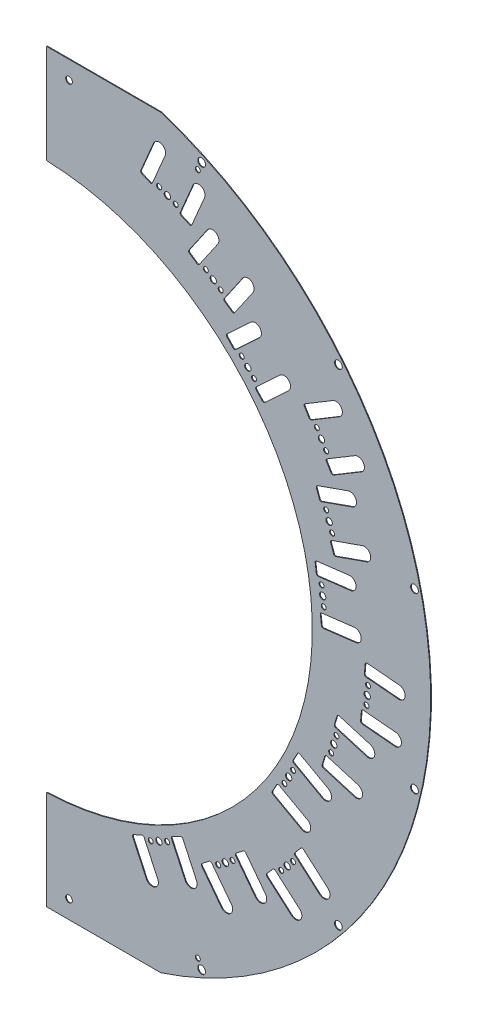
from build123d import *

# Parameters (mm, degrees)
EXTRUDE1_DEPTH                  = 0.205
EXTRUDE3_DEPTH                  = 1.41
STAVE_MOUNT_HOLE_EXTRUDE5_DEPTH = 1.41
MOUSE_HOLE_EXTRUDE7_DEPTH       = 1.205
MOUSE_HOLE_CIRPATTERN5_COUNT    = 4
MOUSE_HOLE_CIRPATTERN5_ANGLE    = 108.15757923
SKETCH14_R                      = 1.85
CUT_EXTRUDE5_DEPTH              = 1
EXTRUDE4_DEPTH                  = 0.41
SKETCH17_R                      = 2.15
SKETCH17_R_2                    = 1.375
CUT_EXTRUDE6_DEPTH              = 1.41
SKETCH18_R                      = 1.375
SKETCH18_R_2                    = 1.75
CUT_EXTRUDE7_DEPTH              = 1.41
CIRPATTERN3_COUNT               = 4
CIRPATTERN3_ANGLE               = 108.15757923


with BuildPart() as part:
    # Sketch1 → Extrude1 (new body, symmetric)
    with BuildSketch(Plane.XY):
        with BuildLine():
            Line((4.5, 217.548779521), (4.5, 151.827758069))
            ThreePointArc((4.5, 151.827758069), (22.508034536, 150.217530607), (40.197176015, 146.479026351))
            ThreePointArc((40.197176015, 146.479026351), (151.89443084, 0), (40.197176015, -146.479026351))
            ThreePointArc((40.197176015, -146.479026351), (22.508034536, -150.217530607), (4.5, -151.827758069))
            Line((4.5, -151.827758069), (4.5, -217.548779521))
            ThreePointArc((4.5, -217.548779521), (217.59531583, 0), (4.5, 217.548779521))
        make_face()
    extrude(amount=EXTRUDE1_DEPTH, both=True)

    # Sketch3 → Extrude3 (cut, through all)
    with BuildSketch(Plane.XY.offset(0.205)):
        with BuildLine():
            Line((4.5, 217.548779521), (4.5, 206.75))
            Line((4.5, 206.75), (67.839214111, 206.75))
            ThreePointArc((67.839214111, 206.75), (36.570396283, 214.500180855), (4.5, 217.548779521))
        make_face()
        with BuildLine():
            Line((67.839214111, -206.75), (4.5, -206.75))
            Line((4.5, -206.75), (4.5, -217.548779521))
            ThreePointArc((4.5, -217.548779521), (36.570396283, -214.500180855), (67.839214111, -206.75))
        make_face()
    extrude(amount=-EXTRUDE3_DEPTH, mode=Mode.SUBTRACT)

    # Sketch12 → Stave Mount Hole Extrude5 (cut, through all)
    with BuildSketch(Plane.XY.offset(0.205)):
        with BuildLine():
            Line((78.554005798, 168.04877199), (66.124274411, 173.316767591))
            ThreePointArc((66.124274411, 173.316767591), (65.741603761, 173.319895419), (65.468803041, 173.051518117))
            Line((65.468803041, 173.051518117), (64.070247765, 169.751654614))
            ThreePointArc((64.070247765, 169.751654614), (64.067119936, 169.368983964), (64.335497238, 169.096183244))
            Line((64.335497238, 169.096183244), (76.765228625, 163.828187644))
            ThreePointArc((76.765228625, 163.828187644), (77.147899275, 163.825059815), (77.420699995, 164.093437117))
            Line((77.420699995, 164.093437117), (78.819255272, 167.393300621))
            ThreePointArc((78.819255272, 167.393300621), (78.8223831, 167.77597127), (78.554005798, 168.04877199))
        make_face()
        with BuildLine():
            Line((103.782710447, 138.874719717), (92.662330225, 146.52894363))
            ThreePointArc((92.662330225, 146.52894363), (92.288064798, 146.608768433), (91.966974516, 146.400567471))
            Line((91.966974516, 146.400567471), (89.934919812, 143.448312455))
            ThreePointArc((89.934919812, 143.448312455), (89.855095009, 143.074047027), (90.063295972, 142.752956746))
            Line((90.063295972, 142.752956746), (101.183676194, 135.098732832))
            ThreePointArc((101.183676194, 135.098732832), (101.557941621, 135.018908029), (101.879031902, 135.227108992))
            Line((101.879031902, 135.227108992), (103.911086607, 138.179364008))
            ThreePointArc((103.911086607, 138.179364008), (103.990911409, 138.553629435), (103.782710447, 138.874719717))
        make_face()
        with BuildLine():
            Line((122.392786555, 104.971179279), (113.182782772, 114.841631666))
            ThreePointArc((113.182782772, 114.841631666), (112.834507043, 115.000221154), (112.47609921, 114.866092726))
            Line((112.47609921, 114.866092726), (109.855676888, 112.421007277))
            ThreePointArc((109.855676888, 112.421007277), (109.6970874, 112.072731548), (109.831215828, 111.714323715))
            Line((109.831215828, 111.714323715), (119.041219611, 101.843871328))
            ThreePointArc((119.041219611, 101.843871328), (119.38949534, 101.685281841), (119.747903172, 101.819410269))
            Line((119.747903172, 101.819410269), (122.368325495, 104.264495717))
            ThreePointArc((122.368325495, 104.264495717), (122.526914983, 104.612771447), (122.392786555, 104.971179279))
        make_face()
    extrude(amount=-STAVE_MOUNT_HOLE_EXTRUDE5_DEPTH, mode=Mode.SUBTRACT)

    # Sketch15 → Mouse Hole Extrude7 (cut, symmetric)
    with BuildSketch(Plane.XY):
        with BuildLine():
            Line((63.756596481, 189.833087254), (56.732602347, 173.260112071))
            ThreePointArc((56.732602347, 173.260112071), (56.72634669, 172.494770772), (57.263101294, 171.949169331))
            Line((57.263101294, 171.949169331), (61.866705512, 169.99805985))
            ThreePointArc((61.866705512, 169.99805985), (62.632046811, 169.991804192), (63.177648252, 170.528558797))
            Line((63.177648252, 170.528558797), (70.201642385, 187.10153398))
            ThreePointArc((70.201642385, 187.10153398), (68.34489607, 191.689833569), (63.756596481, 189.833087254))
        make_face()
        with BuildLine():
            Line((93.655811762, 163.184504516), (83.450179877, 148.357330887))
            ThreePointArc((83.450179877, 148.357330887), (83.290530271, 147.608800032), (83.706932196, 146.96661947))
            Line((83.706932196, 146.96661947), (87.825591537, 144.131721724))
            ThreePointArc((87.825591537, 144.131721724), (88.574122393, 143.972072118), (89.216302955, 144.388474043))
            Line((89.216302955, 144.388474043), (99.42193484, 159.215647672))
            ThreePointArc((99.42193484, 159.215647672), (98.523301723, 164.083137633), (93.655811762, 163.184504516))
        make_face()
        with BuildLine():
            Line((117.741552315, 130.891938027), (104.580949132, 118.611932984))
            ThreePointArc((104.580949132, 118.611932984), (104.263770157, 117.915381524), (104.532027013, 117.19856586))
            Line((104.532027013, 117.19856586), (107.943139525, 113.542842754))
            ThreePointArc((107.943139525, 113.542842754), (108.639690984, 113.225663778), (109.356506648, 113.493920635))
            Line((109.356506648, 113.493920635), (122.517109831, 125.773925678))
            ThreePointArc((122.517109831, 125.773925678), (122.688337248, 130.720710611), (117.741552315, 130.891938027))
        make_face()
        with BuildLine():
            Line((120.783733564, 101.247248228), (133.944336747, 113.527253271))
            ThreePointArc((133.944336747, 113.527253271), (138.89112168, 113.356025855), (138.719894263, 108.409240923))
            Line((138.719894263, 108.409240923), (125.55929108, 96.129235879))
            ThreePointArc((125.55929108, 96.129235879), (124.842475416, 95.860979023), (124.145923957, 96.178157998))
            Line((124.145923957, 96.178157998), (120.734811445, 99.833881105))
            ThreePointArc((120.734811445, 99.833881105), (120.466554589, 100.550696769), (120.783733564, 101.247248228))
        make_face()
        with BuildLine():
            Line((107.389223409, 130.665957432), (103.270564068, 133.500855177))
            ThreePointArc((103.270564068, 133.500855177), (102.854162143, 134.14303574), (103.013811749, 134.891566595))
            Line((103.013811749, 134.891566595), (113.219443634, 149.718740224))
            ThreePointArc((113.219443634, 149.718740224), (118.086933595, 150.617373341), (118.985566712, 145.74988338))
            Line((118.985566712, 145.74988338), (108.779934827, 130.922709751))
            ThreePointArc((108.779934827, 130.922709751), (108.137754265, 130.506307826), (107.389223409, 130.665957432))
        make_face()
        with BuildLine():
            Line((83.733825545, 160.730289812), (79.130221327, 162.681399294))
            ThreePointArc((79.130221327, 162.681399294), (78.593466723, 163.227000734), (78.59972238, 163.992342034))
            Line((78.59972238, 163.992342034), (85.623716514, 180.565317217))
            ThreePointArc((85.623716514, 180.565317217), (90.212016103, 182.422063532), (92.068762418, 177.833763942))
            Line((92.068762418, 177.833763942), (85.044768285, 161.26078876))
            ThreePointArc((85.044768285, 161.26078876), (84.499166844, 160.724034155), (83.733825545, 160.730289812))
        make_face()
    mouse_hole_extrude7 = extrude(amount=MOUSE_HOLE_EXTRUDE7_DEPTH, both=True, mode=Mode.SUBTRACT)

    # Mouse Hole CirPattern5: Mouse Hole Extrude7 ×4 about axis
    mouse_hole_cirpattern5_axis = Axis((0, 0, 0), (0, 0, -1))
    for i in range(1, MOUSE_HOLE_CIRPATTERN5_COUNT):
        add(mouse_hole_extrude7.rotate(mouse_hole_cirpattern5_axis, i * MOUSE_HOLE_CIRPATTERN5_ANGLE / (MOUSE_HOLE_CIRPATTERN5_COUNT - 1)), mode=Mode.SUBTRACT)

    # Sketch14 → Cut-Extrude5 (cut)
    with BuildSketch(Plane.XY.offset(0.205)):
        with Locations((16.866246808, 196.75)):
            Circle(SKETCH14_R)
        with Locations((16.866246808, -196.75)):
            Circle(SKETCH14_R)
    extrude(amount=-CUT_EXTRUDE5_DEPTH, mode=Mode.SUBTRACT)

    # Sketch16 → Extrude4 (add)
    with BuildSketch(Plane.XY.offset(0.205)):
        with BuildLine():
            Line((77.420699995, 164.093437117), (78.819255272, 167.393300621))
            ThreePointArc((78.819255272, 167.393300621), (78.8223831, 167.77597127), (78.554005798, 168.04877199))
            Line((78.554005798, 168.04877199), (66.124274411, 173.316767591))
            ThreePointArc((66.124274411, 173.316767591), (65.741603761, 173.319895419), (65.468803041, 173.051518117))
            Line((65.468803041, 173.051518117), (64.070247765, 169.751654614))
            ThreePointArc((64.070247765, 169.751654614), (64.067119936, 169.368983964), (64.335497238, 169.096183244))
            Line((64.335497238, 169.096183244), (76.765228625, 163.828187644))
            ThreePointArc((76.765228625, 163.828187644), (77.147899275, 163.825059815), (77.420699995, 164.093437117))
        make_face()
        with BuildLine():
            Line((103.782710447, 138.874719717), (92.662330225, 146.52894363))
            ThreePointArc((92.662330225, 146.52894363), (92.288064798, 146.608768433), (91.966974516, 146.400567471))
            Line((91.966974516, 146.400567471), (89.934919812, 143.448312455))
            ThreePointArc((89.934919812, 143.448312455), (89.855095009, 143.074047027), (90.063295972, 142.752956746))
            Line((90.063295972, 142.752956746), (101.183676194, 135.098732832))
            ThreePointArc((101.183676194, 135.098732832), (101.557941621, 135.018908029), (101.879031902, 135.227108992))
            Line((101.879031902, 135.227108992), (103.911086607, 138.179364008))
            ThreePointArc((103.911086607, 138.179364008), (103.990911409, 138.553629435), (103.782710447, 138.874719717))
        make_face()
        with BuildLine():
            Line((112.47609921, 114.866092726), (109.855676888, 112.421007277))
            ThreePointArc((109.855676888, 112.421007277), (109.6970874, 112.072731548), (109.831215828, 111.714323715))
            Line((109.831215828, 111.714323715), (119.041219611, 101.843871328))
            ThreePointArc((119.041219611, 101.843871328), (119.38949534, 101.685281841), (119.747903172, 101.819410269))
            Line((119.747903172, 101.819410269), (122.368325495, 104.264495717))
            ThreePointArc((122.368325495, 104.264495717), (122.526914983, 104.612771447), (122.392786555, 104.971179279))
            Line((122.392786555, 104.971179279), (113.182782772, 114.841631666))
            ThreePointArc((113.182782772, 114.841631666), (112.834507043, 115.000221154), (112.47609921, 114.866092726))
        make_face()
    extrude(amount=-EXTRUDE4_DEPTH)

    # Sketch17 → Cut-Extrude6 (cut, through all)
    with BuildSketch(Plane(origin=(0, 0, -0.205), x_dir=(-1, 0, 0), z_dir=(0, 0, -1))):
        with Locations((-90.466932963, 194.006963816)):
            Circle(SKETCH17_R)
        with Locations((-88.353841654, 189.475424881)):
            Circle(SKETCH17_R_2)
        with Locations((-166.358195947, 134.714210869)):
            Circle(SKETCH17_R)
        with Locations((-208.576579178, 48.153697546)):
            Circle(SKETCH17_R)
        with Locations((-208.576579178, -48.153697546)):
            Circle(SKETCH17_R)
        with Locations((-90.466932963, -194.006963816)):
            Circle(SKETCH17_R)
        with Locations((-88.353841654, -189.475424881)):
            Circle(SKETCH17_R_2)
        with Locations((-166.358195947, -134.714210869)):
            Circle(SKETCH17_R)
    extrude(amount=-CUT_EXTRUDE6_DEPTH, mode=Mode.SUBTRACT)

    # Sketch18 → Cut-Extrude7 (cut, through all)
    with BuildSketch(Plane.XY.offset(0.205)):
        with Locations((76.048355736, 166.621368136)):
            Circle(SKETCH18_R)
        with Locations((96.923003209, 140.813838231)):
            Circle(SKETCH18_R_2)
        with Locations((71.444751518, 168.572477617)):
            Circle(SKETCH18_R_2)
        with Locations((116.112001191, 108.342751497)):
            Circle(SKETCH18_R_2)
        with Locations((66.841147301, 170.523587099)):
            Circle(SKETCH18_R)
        with Locations((92.804343868, 143.648735977)):
            Circle(SKETCH18_R)
        with Locations((101.041662551, 137.978940485)):
            Circle(SKETCH18_R)
        with Locations((119.523113703, 104.687028391)):
            Circle(SKETCH18_R)
        with Locations((112.700888679, 111.998474604)):
            Circle(SKETCH18_R)
    cut_extrude7 = extrude(amount=-CUT_EXTRUDE7_DEPTH, mode=Mode.SUBTRACT)

    # CirPattern3: Cut-Extrude7 ×4 about axis
    cirpattern3_axis = Axis((0, 0, 0), (0, 0, -1))
    for i in range(1, CIRPATTERN3_COUNT):
        add(cut_extrude7.rotate(cirpattern3_axis, i * CIRPATTERN3_ANGLE / (CIRPATTERN3_COUNT - 1)), mode=Mode.SUBTRACT)


solid = part.part
